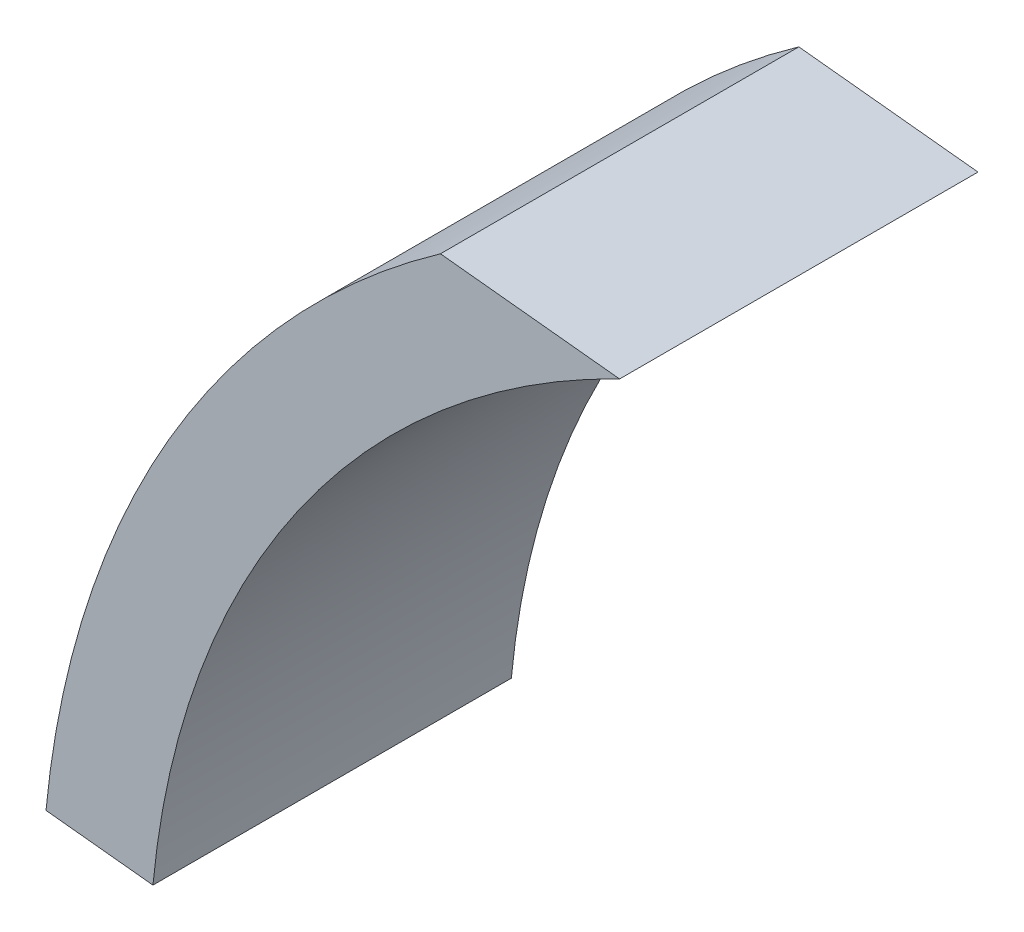
from build123d import *

# Parameters (mm, degrees)
EXTRUDE_1_DEPTH          = 6.15
CUT_EXTRUDE_1_DEPTH      = 17.072414255
CUT_EXTRUDE_1_DEPTH_BACK = 17.072414255


with BuildPart() as part:
    # 草图1 → 凸台-拉伸1 (new body)
    with BuildSketch(Plane.XY):
        with BuildLine():
            Line((-9.3, 0), (-10.5, 0))
            ThreePointArc((-10.5, 0), (-0.549527541, 10.485610115), (10.442479901, 1.097548864))
            Line((10.442479901, 1.097548864), (9.249053627, 0.972114708))
            ThreePointArc((9.249053627, 0.972114708), (-0.486724393, 9.287254673), (-9.3, 0))
        make_face()
    extrude(amount=EXTRUDE_1_DEPTH)

    # 草图4 → 切除-拉伸1 (cut, two sides)
    with BuildSketch(Plane(origin=(0, 0, 6.15), x_dir=(0, 0, 1), z_dir=(-0.9945218953682734, 0.10452846326765432, 0))) as cut_extrude_1_sk:
        Polygon((0, -0.097548864), (-4, -0.097548864), (-4, 7.902451136), (0, 7.902451136), (0, 10.5), (-6.15, 10.5), (-6.15, -1.097548864), (0, -1.097548864), align=None)
    extrude(amount=CUT_EXTRUDE_1_DEPTH, mode=Mode.SUBTRACT)
    extrude(cut_extrude_1_sk.sketch, amount=-CUT_EXTRUDE_1_DEPTH_BACK, mode=Mode.SUBTRACT)


with BuildPart() as body_2:
    # of the pieces the cut leaves, the one that is kept (cut_extrude_1_keep)
    add(part.part.solids().sort_by_distance((-4.050298117, 8.371683532, 6.15))[0])


solid = body_2.part
